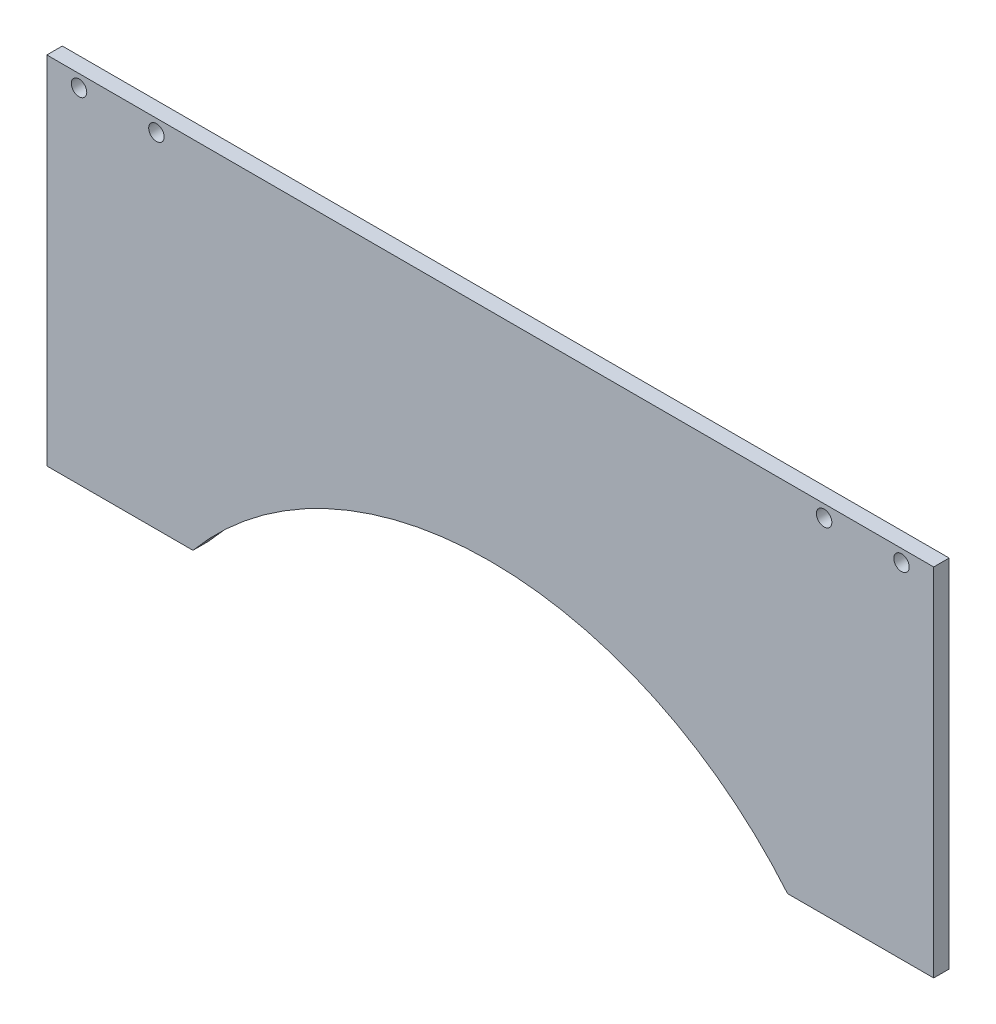
from build123d import *

# Parameters (mm, degrees)
SKETCH6_W           = 286.5
SKETCH6_H           = 115
BOSS_EXTRUDE3_DEPTH = 5
SKETCH7_R           = 2.5
CUT_EXTRUDE1_DEPTH  = 13
SKETCH8_R           = 125
CUT_EXTRUDE4_DEPTH  = 10


with BuildPart() as part:
    # Sketch6 → Boss-Extrude3 (new body)
    with BuildSketch(Plane.XY):
        with Locations((18.25, 57.5)):
            Rectangle(SKETCH6_W, SKETCH6_H)
    extrude(amount=BOSS_EXTRUDE3_DEPTH)

    # Sketch7 → Cut-Extrude1 (cut)
    with BuildSketch(Plane.XY.offset(5)):
        with Locations((151.1, 111)):
            Circle(SKETCH7_R)
        with Locations((126.1, 111)):
            Circle(SKETCH7_R)
        with Locations((-114.6, 111)):
            Circle(SKETCH7_R)
        with Locations((-89.6, 111)):
            Circle(SKETCH7_R)
    extrude(amount=-CUT_EXTRUDE1_DEPTH, mode=Mode.SUBTRACT)

    # Sketch8 → Cut-Extrude4 (cut)
    with BuildSketch(Plane.XY.offset(5)):
        with Locations((18.25, -80)):
            Circle(SKETCH8_R)
    extrude(amount=-CUT_EXTRUDE4_DEPTH, mode=Mode.SUBTRACT)


solid = part.part
